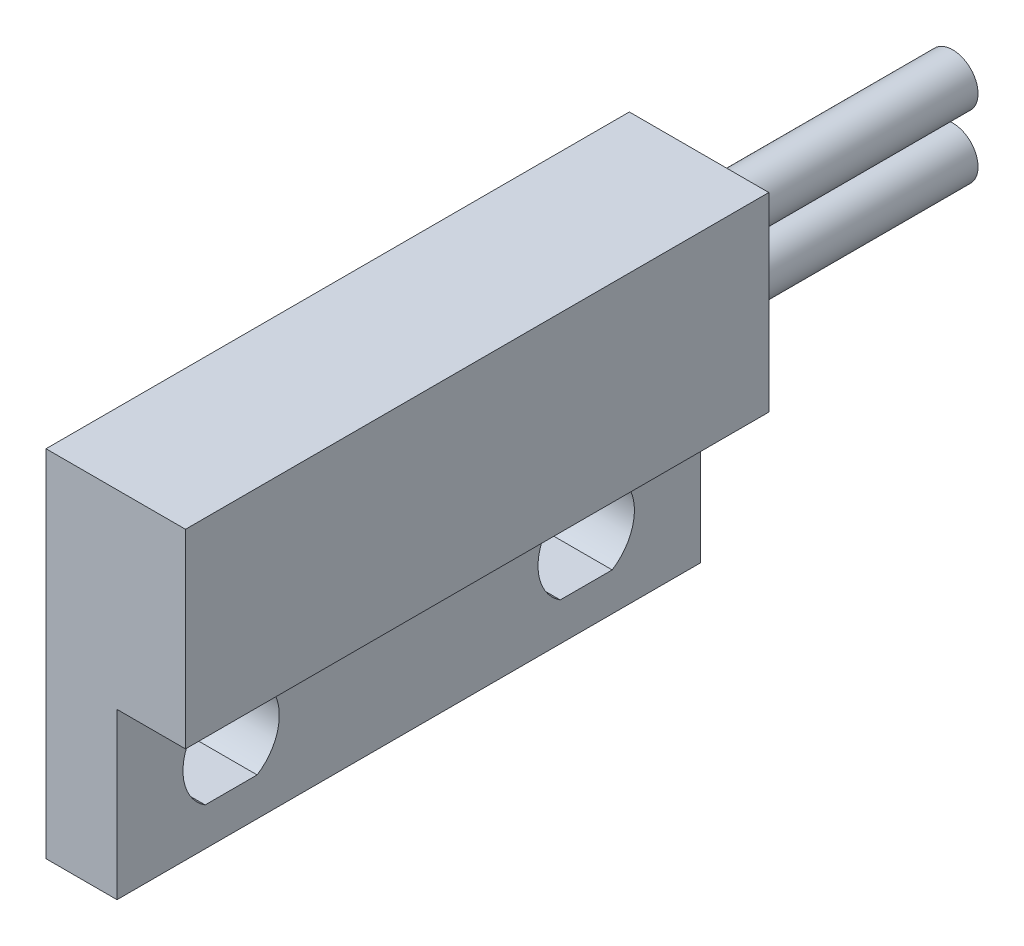
from build123d import *

# Parameters (mm, degrees)
DODANIE_WYCI_GNI_CIE1_DEPTH = 11.5
SZKIC2_R                    = 1
DODANIE_WYCI_GNI_CIE2_DEPTH = 10
WYTNIJ_WYCI_GNI_CIE1_DEPTH  = 10


with BuildPart() as part:
    # Szkic1 → Dodanie-wyciągnięcie1 (new body, symmetric)
    with BuildSketch(Plane.XY):
        Polygon((0, 0), (0, 14), (5.5, 14), (5.5, 6.5), (2.8, 6.5), (2.8, 0), align=None)
    extrude(amount=DODANIE_WYCI_GNI_CIE1_DEPTH, both=True)

    # Szkic2 → Dodanie-wyciągnięcie2 (add)
    with BuildSketch(Plane(origin=(0, 0, -11.5), x_dir=(-1, 0, 0), z_dir=(0, 0, -1))):
        with Locations((-2.75, 11.5)):
            Circle(SZKIC2_R)
        with Locations((-2.75, 9)):
            Circle(SZKIC2_R)
    extrude(amount=DODANIE_WYCI_GNI_CIE2_DEPTH)

    # Szkic3 → Wytnij-wyciągnięcie1 (cut)
    with BuildSketch(Plane(origin=(2.8, 0, 0), x_dir=(0, 0, -1), z_dir=(1, 0, 0))):
        with BuildLine():
            Line((-8.024695077, 1.5), (-5.975304923, 1.5))
            ThreePointArc((-5.975304923, 1.5), (-5.1, 3.1), (-5.975304923, 4.7))
            Line((-5.975304923, 4.7), (-8.024695077, 4.7))
            ThreePointArc((-8.024695077, 4.7), (-8.9, 3.1), (-8.024695077, 1.5))
        make_face()
        with BuildLine():
            Line((8.024695077, 1.5), (5.975304923, 1.5))
            ThreePointArc((5.975304923, 1.5), (5.1, 3.1), (5.975304923, 4.7))
            Line((5.975304923, 4.7), (8.024695077, 4.7))
            ThreePointArc((8.024695077, 4.7), (8.9, 3.1), (8.024695077, 1.5))
        make_face()
    extrude(amount=-WYTNIJ_WYCI_GNI_CIE1_DEPTH, mode=Mode.SUBTRACT)


solid = part.part
